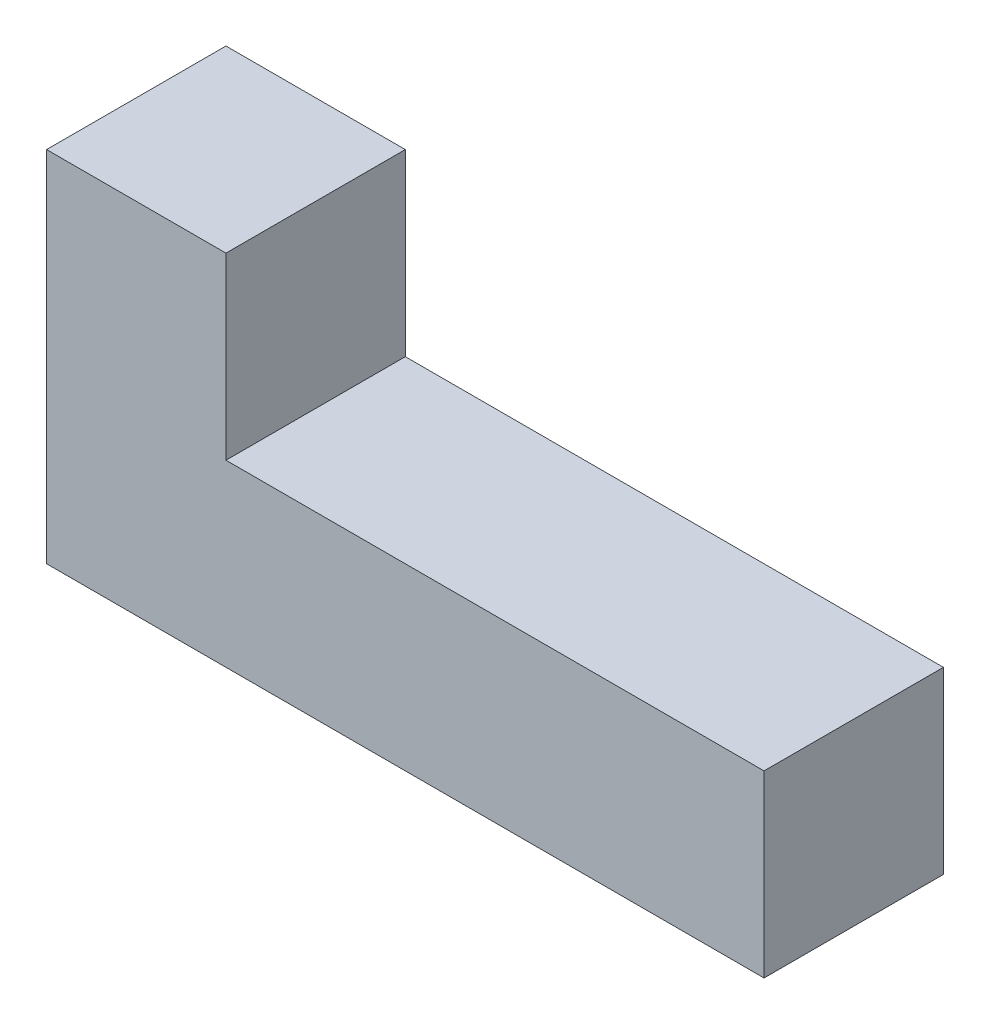
from build123d import *

# Parameters (mm, degrees)
BOSS_EXTRUDE1_DEPTH = 25.4


with BuildPart() as part:
    # Sketch1 → Boss-Extrude1 (new body)
    with BuildSketch(Plane.XY):
        Polygon((101.6, 0), (101.6, 25.4), (25.4, 25.4), (25.4, 50.8), (0, 50.8), (0, 0), align=None)
    extrude(amount=BOSS_EXTRUDE1_DEPTH)


solid = part.part
